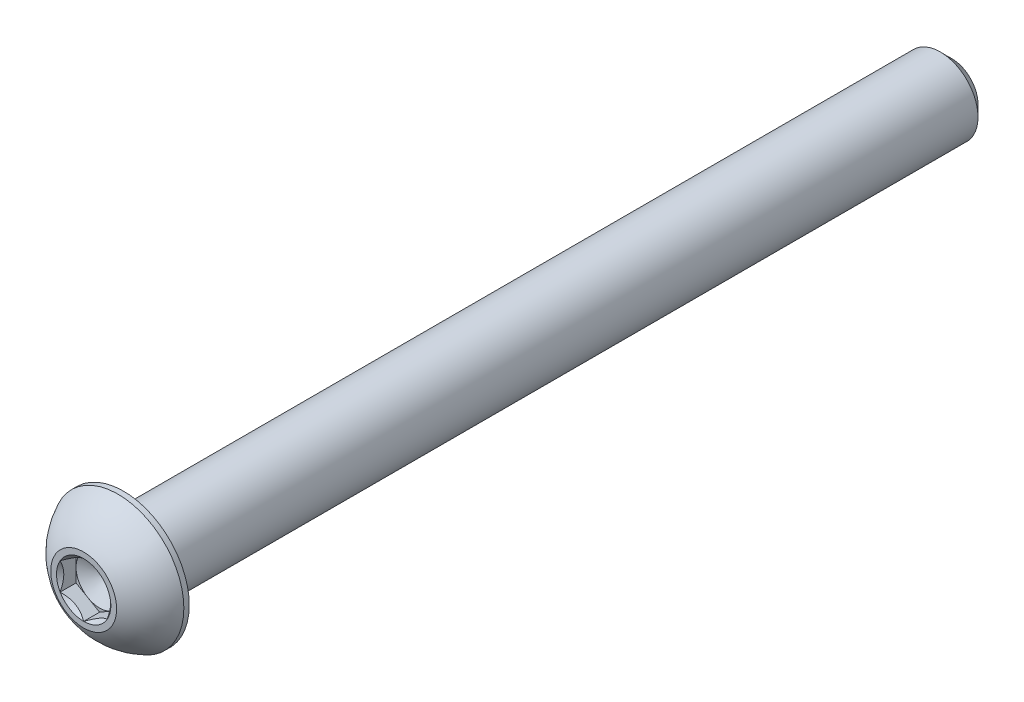
from build123d import *

# Parameters (mm, degrees)
CUT_EXTRUDE1_START = 35.26028
CUT_EXTRUDE1_DEPTH = 2.34112
SKETCH4_R          = 2.291358881
CUT_EXTRUDE2_DEPTH = 1.34112
CUT_EXTRUDE2_DRAFT = -45


with BuildPart() as part:
    # Sketch2 → Revolve1 (revolve)
    with BuildSketch(Plane(origin=(0, 0, 0), x_dir=(0, 0, -1), z_dir=(1, 0, 0))):
        with BuildLine():
            Line((-36.6014, 1.984375), (-36.6014, 2.778125))
            ThreePointArc((-36.6014, 2.778125), (-35.386122602, 4.40912482), (-33.702171429, 5.5499))
            Line((-33.702171429, 5.5499), (-33.2486, 5.5499))
            Line((-33.2486, 5.5499), (-33.2486, 3.175))
            Line((-33.2486, 3.175), (35.6489, 3.175))
            Line((35.6489, 3.175), (36.6014, 2.2225))
            Line((36.6014, 2.2225), (36.6014, 0))
            Line((36.6014, 0), (-34.11460056, 0))
            Line((-34.11460056, 0), (-35.26028, 1.984375))
            Line((-35.26028, 1.984375), (-36.6014, 1.984375))
        make_face()
    revolve(axis=Axis((0, 0, 36.6014), (0, 0, -1)))

    # Sketch3 → Cut-Extrude1 (cut, through all)
    with BuildSketch(Plane.XY.offset(CUT_EXTRUDE1_START)):
        Polygon((0, 2.291358881), (-1.984375, 1.14567944), (-1.984375, -1.14567944), (0, -2.291358881), (1.984375, -1.14567944), (1.984375, 1.14567944), align=None)
    extrude(amount=CUT_EXTRUDE1_DEPTH, mode=Mode.SUBTRACT)


with BuildPart() as cut_extrude2_tool:
    # Sketch4 → Cut-Extrude2 (with draft: the straight prism first)
    with BuildSketch(Plane.XY.offset(36.6014)):
        Circle(SKETCH4_R)
    extrude(amount=-CUT_EXTRUDE2_DEPTH)
    # Cut-Extrude2: the draft: its side faces are tilted about the plane it starts from
    cut_extrude2_sides = [cut_extrude2_tool.faces().sort_by_distance(p)[0] for p in [
        (-2.291358881, 0, 35.93084),
    ]]
    draft(cut_extrude2_sides, Plane.XY.offset(36.6014), CUT_EXTRUDE2_DRAFT)


with BuildPart() as part_1:
    add(part.part)

    # Cut-Extrude2: cut by cut_extrude2_tool
    add(cut_extrude2_tool.part, mode=Mode.SUBTRACT)


solid = part_1.part
